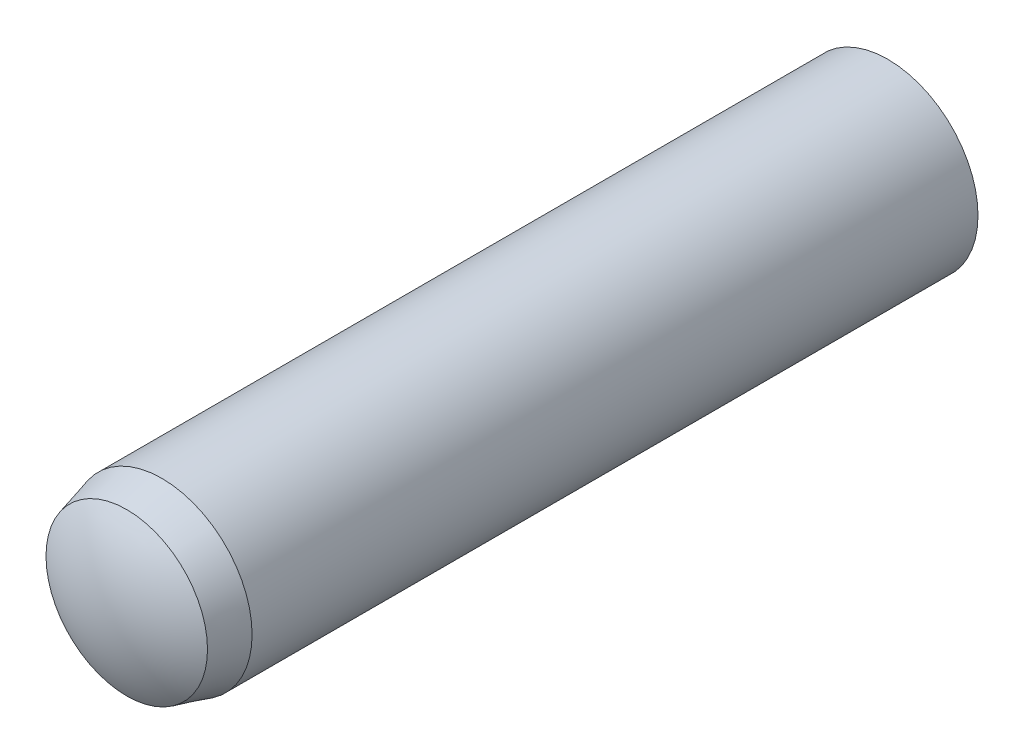
from build123d import *


with BuildPart() as part:
    # Sketch3 → Revolve1 (revolve)
    with BuildSketch(Plane(origin=(0, 0, 0), x_dir=(0, 0, -1), z_dir=(1, 0, 0))):
        with BuildLine():
            Line((-18, 0), (18, 0))
            ThreePointArc((18, 0), (17.693537673, 2.088061302), (16.8, 4))
            Line((16.8, 4), (-15.4, 4))
            Line((-15.4, 4), (-16.96, 3.58199926))
            ThreePointArc((-16.96, 3.58199926), (-17.734740106, 1.864961038), (-18, 0))
        make_face()
    revolve(axis=Axis((0, 0, 18), (0, 0, -1)))


solid = part.part
